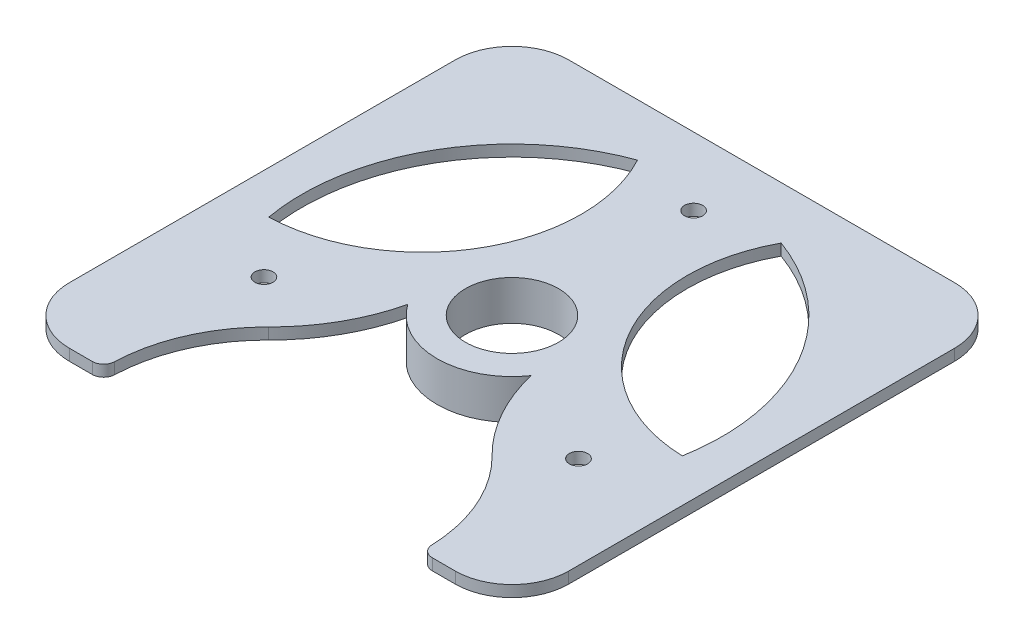
from build123d import *

# Parameters (mm, degrees)
SKETCH1_W                = 88
SKETCH1_H                = 88
BOSS_EXTRUDE1_DEPTH      = 2
FILLET1_R                = 10
SKETCH3_R                = 37
CUT_EXTRUDE2_DEPTH       = 3
SKETCH5_R                = 40.5
SKETCH5_R_2              = 10
BOSS_EXTRUDE2_DEPTH      = 2
CUT_EXTRUDE3_DEPTH       = 3
CIRPATTERN1_COUNT        = 3
SKETCH17_R               = 27.977706125
CUT_EXTRUDE4_DEPTH       = 3
CUT_EXTRUDE5_DEPTH       = 3
FILLET2_R                = 2
SKETCH19_R               = 13.2
SKETCH19_R_2             = 8.2
BOSS_EXTRUDE3_DEPTH      = 5
BOSS_EXTRUDE3_DEPTH_BACK = 2
SKETCH20_R               = 1.6
CUT_EXTRUDE6_DEPTH       = 3
CIRPATTERN2_COUNT        = 3


with BuildPart() as part:
    # Sketch1 → Boss-Extrude1 (new body)
    with BuildSketch(Plane(origin=(0, 0, 0), x_dir=(1, 0, 0), z_dir=(0, 1, 0))):
        Rectangle(SKETCH1_W, SKETCH1_H)
    extrude(amount=BOSS_EXTRUDE1_DEPTH)

    # Fillet1
    fillet1_edges = [part.edges().sort_by_distance(p)[0] for p in [
        (44, 1, 44),
        (-44, 1, 44),
        (-44, 1, -44),
        (44, 1, -44),
    ]]
    fillet(fillet1_edges, radius=FILLET1_R)

    # Sketch3 → Cut-Extrude2 (cut, through all)
    with BuildSketch(Plane(origin=(0, 2, 0), x_dir=(1, 0, 0), z_dir=(0, 1, 0))):
        Circle(SKETCH3_R)
    extrude(amount=-CUT_EXTRUDE2_DEPTH, mode=Mode.SUBTRACT)

    # Sketch5 → Boss-Extrude2 (add)
    with BuildSketch(Plane(origin=(0, 0, 0), x_dir=(1, 0, 0), z_dir=(0, 1, 0))):
        Circle(SKETCH5_R)
        Circle(SKETCH5_R_2, mode=Mode.SUBTRACT)
    extrude(amount=BOSS_EXTRUDE2_DEPTH)

    # Sketch16 → Cut-Extrude3 (cut, through all)
    with BuildSketch(Plane(origin=(0, 2, 0), x_dir=(1, 0, 0), z_dir=(0, 1, 0))):
        with BuildLine():
            ThreePointArc((12.654745303, 34.768626969), (13.077619626, 7.550367211), (36.437886861, -6.424982574))
            ThreePointArc((36.437886861, -6.424982574), (32.04293994, 18.5), (12.654745303, 34.768626969))
        make_face()
    cut_extrude3 = extrude(amount=-CUT_EXTRUDE3_DEPTH, mode=Mode.SUBTRACT)

    # CirPattern1: Cut-Extrude3 ×3 about axis
    cirpattern1_axis = Axis((0, 0, 0), (0, 1, 0))
    for i in range(1, CIRPATTERN1_COUNT):
        add(cut_extrude3.rotate(cirpattern1_axis, i * 360 / CIRPATTERN1_COUNT), mode=Mode.SUBTRACT)

    # Sketch17 → Cut-Extrude4 (cut, through all)
    with BuildSketch(Plane(origin=(0, 2, 0), x_dir=(1, 0, 0), z_dir=(0, 1, 0))):
        with Locations((0, -43.078440548)):
            Circle(SKETCH17_R)
    extrude(amount=-CUT_EXTRUDE4_DEPTH, mode=Mode.SUBTRACT)

    # Sketch18 → Cut-Extrude5 (cut, through all)
    with BuildSketch(Plane(origin=(0, 2, 0), x_dir=(1, 0, 0), z_dir=(0, 1, 0))):
        with BuildLine():
            ThreePointArc((-10, 0), (-12.516559025, -12.564476209), (-19.677986964, -23.190532939))
            ThreePointArc((-19.677986964, -23.190532939), (0, -15.100734422), (19.677986964, -23.190532939))
            ThreePointArc((19.677986964, -23.190532939), (12.516559025, -12.564476209), (10, 0))
            ThreePointArc((10, 0), (0, -10), (-10, 0))
        make_face()
    extrude(amount=-CUT_EXTRUDE5_DEPTH, mode=Mode.SUBTRACT)

    # Fillet2
    fillet2_edges = [part.edges().sort_by_distance(p)[0] for p in [
        (-27.962524354, 1, 44),
        (27.962524354, 1, 44),
    ]]
    fillet(fillet2_edges, radius=FILLET2_R)

    # Sketch19 → Boss-Extrude3 (add, two sides)
    with BuildSketch(Plane.XZ) as boss_extrude3_sk:
        Circle(SKETCH19_R)
        Circle(SKETCH19_R_2, mode=Mode.SUBTRACT)
    extrude(amount=BOSS_EXTRUDE3_DEPTH)
    extrude(boss_extrude3_sk.sketch, amount=-BOSS_EXTRUDE3_DEPTH_BACK)

    # Sketch20 → Cut-Extrude6 (cut, through all)
    with BuildSketch(Plane.XZ):
        with Locations((0, -32)):
            Circle(SKETCH20_R)
    cut_extrude6 = extrude(amount=-CUT_EXTRUDE6_DEPTH, mode=Mode.SUBTRACT)

    # CirPattern2: Cut-Extrude6 ×3 about axis
    cirpattern2_axis = Axis((0, 0, 0), (0, 1, 0))
    for i in range(1, CIRPATTERN2_COUNT):
        add(cut_extrude6.rotate(cirpattern2_axis, i * 360 / CIRPATTERN2_COUNT), mode=Mode.SUBTRACT)


solid = part.part
